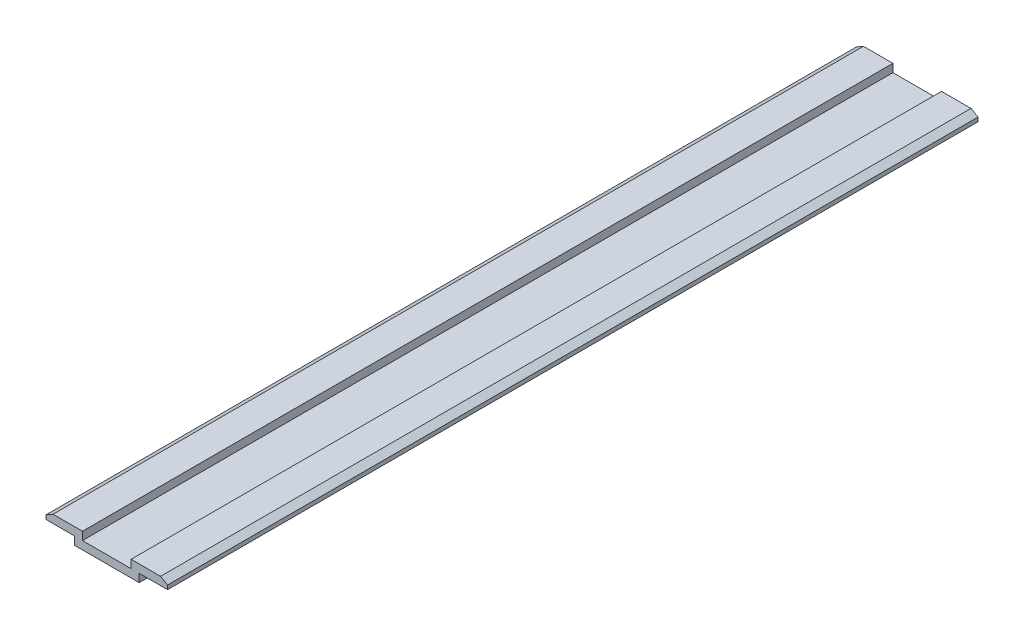
from build123d import *

# Parameters (mm, degrees)
RESSALTO_EXTRUS_O1_DEPTH = 100


with BuildPart() as part:
    # Esboço1 → Ressalto-extrusão1 (new body)
    with BuildSketch(Plane.XY):
        Polygon((4, 0), (-4, 0), (-4, 1), (-7.5, 1), (-7.5, 1.5), (-6.633974596, 2), (-3, 2), (-3, 1), (3, 1), (3, 2), (6.633974596, 2), (7.5, 1.5), (7.5, 1), (4, 1), align=None)
    extrude(amount=RESSALTO_EXTRUS_O1_DEPTH)


solid = part.part
